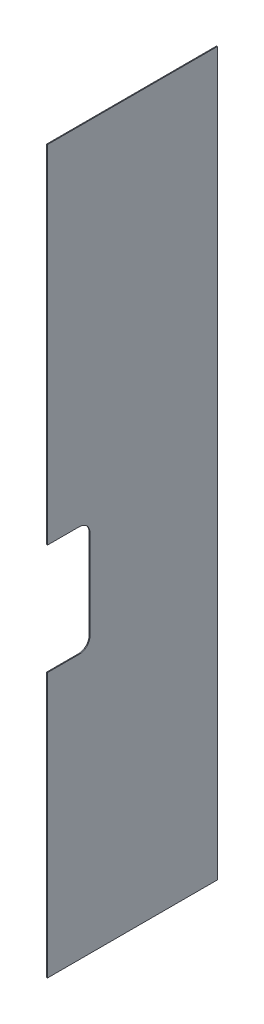
from build123d import *

# Parameters (mm, degrees)
BOSS_EXTRUDE2_DEPTH = 0.254
CUT_EXTRUDE1_DEPTH  = 1.254
SKETCH13_W          = 222.25
SKETCH13_H          = 69.85
CUT_EXTRUDE3_DEPTH  = 1.254


with BuildPart() as part:
    # Sketch1 → Boss-Extrude2 (new body)
    with BuildSketch(Plane(origin=(0, 0, 0), x_dir=(0, 0, -1), z_dir=(1, 0, 0))):
        with BuildLine():
            Line((0, -234.95), (0, -285.75))
            Line((0, -285.75), (203.2, -285.75))
            ThreePointArc((203.2, -285.75), (216.670384182, -280.170384182), (222.25, -266.7))
            Line((222.25, -266.7), (222.25, 0))
            Line((222.25, 0), (171.45, 0))
            Line((171.45, 0), (171.45, -215.9))
            ThreePointArc((171.45, -215.9), (165.870384182, -229.370384182), (152.4, -234.95))
            Line((152.4, -234.95), (0, -234.95))
        make_face()
    extrude(amount=BOSS_EXTRUDE2_DEPTH)

    # Sketch11 → Cut-Extrude1 (cut, through all)
    with BuildSketch(Plane.ZY):
        with BuildLine():
            Line((-171.45, -103.759), (-180.975, -103.759))
            ThreePointArc((-180.975, -103.759), (-183.22006403, -104.68893597), (-184.15, -106.934))
            Line((-184.15, -106.934), (-184.15, -133.604))
            ThreePointArc((-184.15, -133.604), (-183.22006403, -135.84906403), (-180.975, -136.779))
            Line((-180.975, -136.779), (-171.45, -136.779))
            Line((-171.45, -136.779), (-171.45, -103.759))
        make_face()
        with BuildLine():
            Line((-44.45, -234.95), (-31.75, -234.95))
            Line((-31.75, -234.95), (-31.75, -244.475))
            ThreePointArc((-31.75, -244.475), (-32.67993597, -246.72006403), (-34.925, -247.65))
            Line((-34.925, -247.65), (-41.275, -247.65))
            ThreePointArc((-41.275, -247.65), (-43.52006403, -246.72006403), (-44.45, -244.475))
            Line((-44.45, -244.475), (-44.45, -234.95))
        make_face()
    extrude(amount=-CUT_EXTRUDE1_DEPTH, mode=Mode.SUBTRACT)

    # Sketch13 → Cut-Extrude3 (cut, through all)
    with BuildSketch(Plane.ZY):
        with Locations((-111.125, -250.825)):
            Rectangle(SKETCH13_W, SKETCH13_H)
    extrude(amount=-CUT_EXTRUDE3_DEPTH, mode=Mode.SUBTRACT)


solid = part.part
